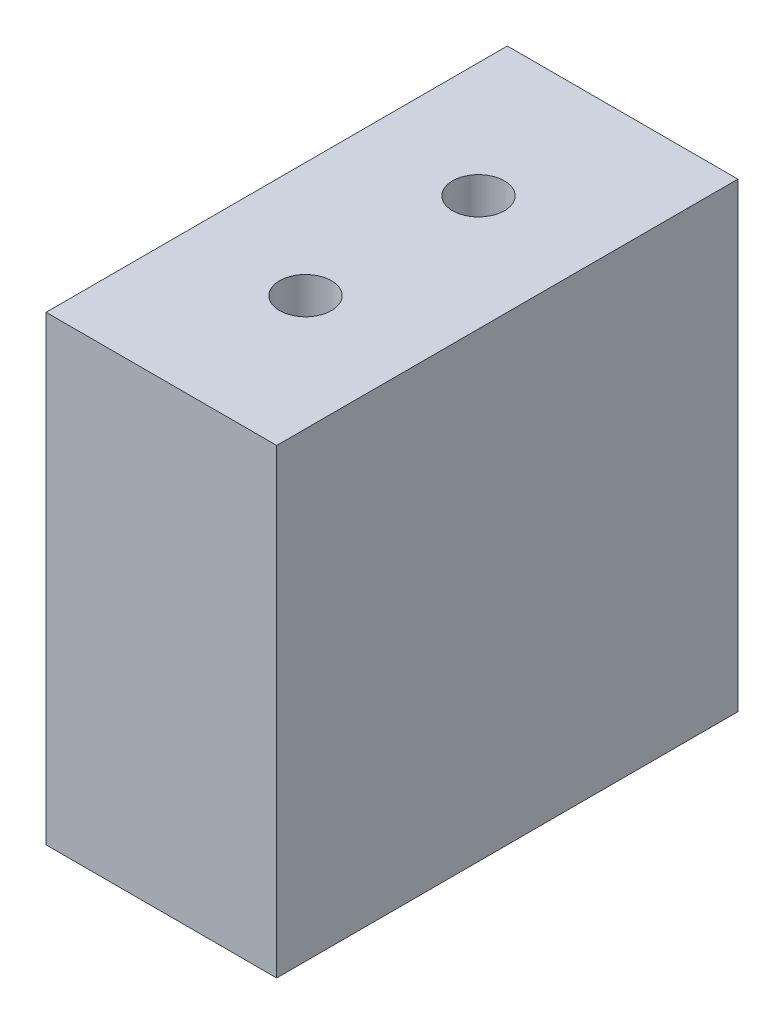
from build123d import *

# Parameters (mm, degrees)
SKETCH_1_W          = 40
SKETCH_1_H          = 40
EXTRUDE_1_DEPTH     = 20
SKETCH_2_R          = 2.25
CUT_EXTRUDE_1_DEPTH = 41


with BuildPart() as part:
    # 草图1 → 凸台-拉伸1 (new body)
    with BuildSketch(Plane(origin=(0, 0, 0), x_dir=(0, 0, -1), z_dir=(1, 0, 0))):
        with Locations((20, 20)):
            Rectangle(SKETCH_1_W, SKETCH_1_H)
    extrude(amount=EXTRUDE_1_DEPTH)

    # 草图2 → 切除-拉伸1 (cut, through all)
    with BuildSketch(Plane(origin=(0, 40, 0), x_dir=(1, 0, 0), z_dir=(0, 1, 0))):
        with Locations((10, 27.5)):
            Circle(SKETCH_2_R)
        with Locations((10, 12.5)):
            Circle(SKETCH_2_R)
    extrude(amount=-CUT_EXTRUDE_1_DEPTH, mode=Mode.SUBTRACT)


solid = part.part
